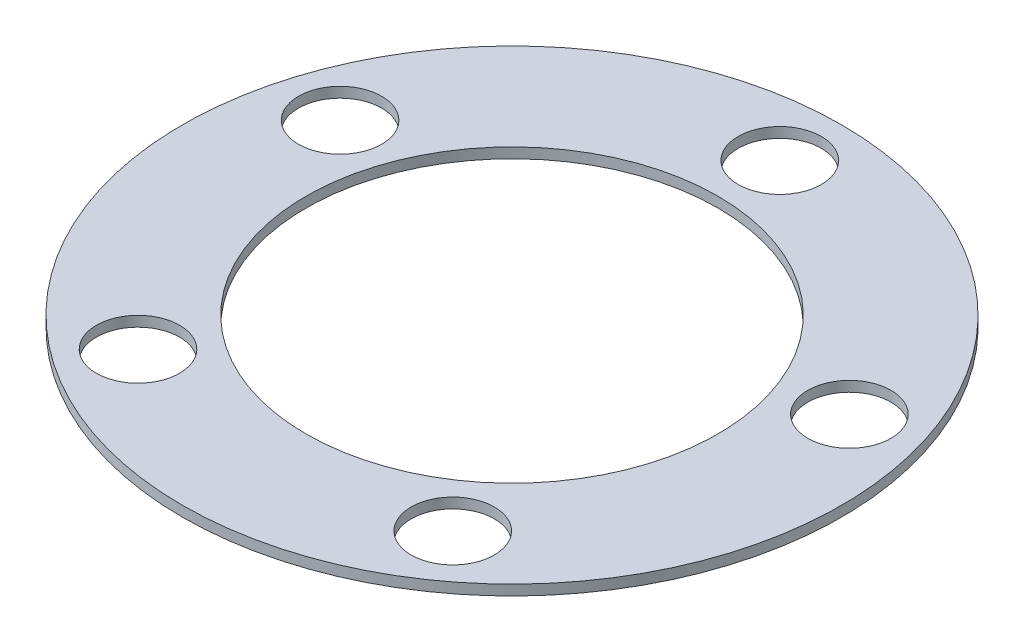
from build123d import *

# Parameters (mm, degrees)
SKETCH1_R           = 101.6
BOSS_EXTRUDE1_DEPTH = 3.175
SKETCH2_R           = 12.827
CUT_EXTRUDE1_DEPTH  = 3.175
SKETCH3_R           = 63.5
CUT_EXTRUDE2_DEPTH  = 4.175


with BuildPart() as part:
    # Sketch1 → Boss-Extrude1 (new body)
    with BuildSketch(Plane(origin=(0, 0, 0), x_dir=(1, 0, 0), z_dir=(0, 1, 0))):
        Circle(SKETCH1_R)
    extrude(amount=BOSS_EXTRUDE1_DEPTH)

    # Sketch2 → Cut-Extrude1 (cut)
    with BuildSketch(Plane(origin=(0, 3.175, 0), x_dir=(1, 0, 0), z_dir=(0, 1, 0))):
        with Locations((0, 82.55)):
            Circle(SKETCH2_R)
        with Locations((78.50971542, 25.509352886)):
            Circle(SKETCH2_R)
        with Locations((48.521672577, -66.784352886)):
            Circle(SKETCH2_R)
        with Locations((-48.521672577, -66.784352886)):
            Circle(SKETCH2_R)
        with Locations((-78.50971542, 25.509352886)):
            Circle(SKETCH2_R)
    extrude(amount=-CUT_EXTRUDE1_DEPTH, mode=Mode.SUBTRACT)

    # Sketch3 → Cut-Extrude2 (cut, through all)
    with BuildSketch(Plane(origin=(0, 3.175, 0), x_dir=(1, 0, 0), z_dir=(0, 1, 0))):
        Circle(SKETCH3_R)
    extrude(amount=-CUT_EXTRUDE2_DEPTH, mode=Mode.SUBTRACT)


solid = part.part
